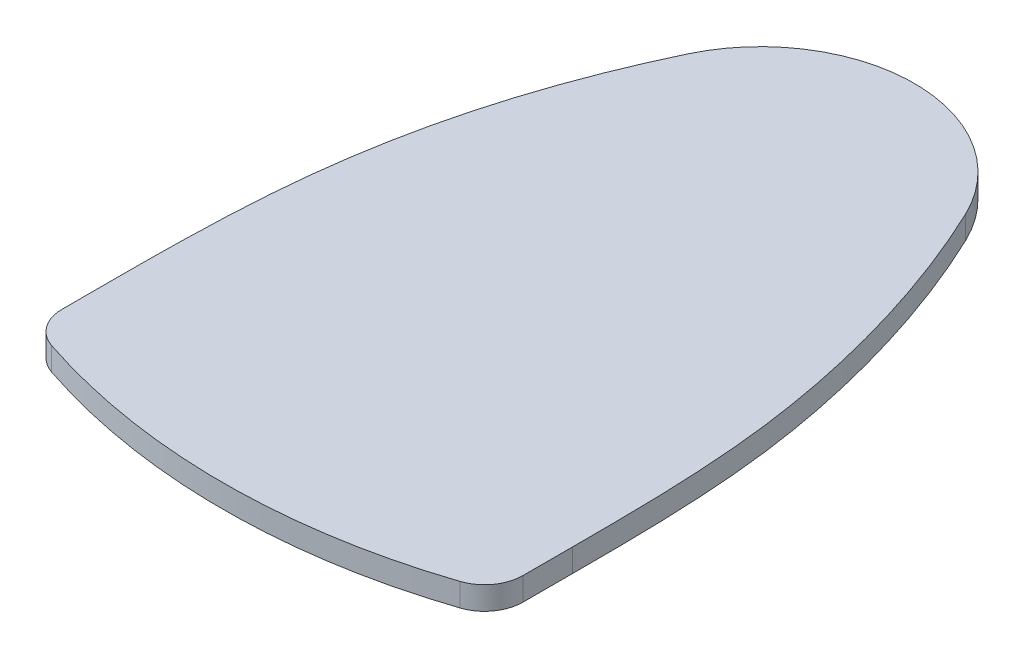
from build123d import *

# Parameters (mm, degrees)
EXTRUDE_1_DEPTH = 3
FILLET_1_R      = 5


with BuildPart() as part:
    # 草图1 → 凸台-拉伸1 (new body)
    with BuildSketch(Plane(origin=(0, 0, 0), x_dir=(1, 0, 0), z_dir=(0, 1, 0))):
        with BuildLine():
            add(Edge.make_bspline(
                [(-18.059479814, 8.593904168), (-23.948193256, -3.780809287), (-29.696472288, -24.34126392), (-30, -45.953108691), (-30, -54.460180984)],
                knots=[0, 0, 0, 0, 0.608662134, 1, 1, 1, 1], degree=3))
            Line((-30, -54.460180984), (-30, -64.460180984))
            ThreePointArc((-30, -64.460180984), (0, -70), (30, -64.460180984))
            Line((30, -64.460180984), (30, -54.460180984))
            add(Edge.make_bspline(
                [(18.059479814, 8.593904168), (23.423782854, -2.678798038), (29.865056496, -24.432184966), (30, -46.291744963), (30, -54.460180984)],
                knots=[0, 0, 0, 0, 0.608662134, 1, 1, 1, 1], degree=3))
            ThreePointArc((18.059479814, 8.593904168), (0, 20), (-18.059479814, 8.593904168))
        make_face()
    extrude(amount=EXTRUDE_1_DEPTH)

    # 圆角1
    fillet_1_edges = [part.edges().sort_by_distance(p)[0] for p in [
        (30, 1.5, 64.460180984),
        (-30, 1.5, 64.460180984),
    ]]
    fillet(fillet_1_edges, radius=FILLET_1_R)


solid = part.part
